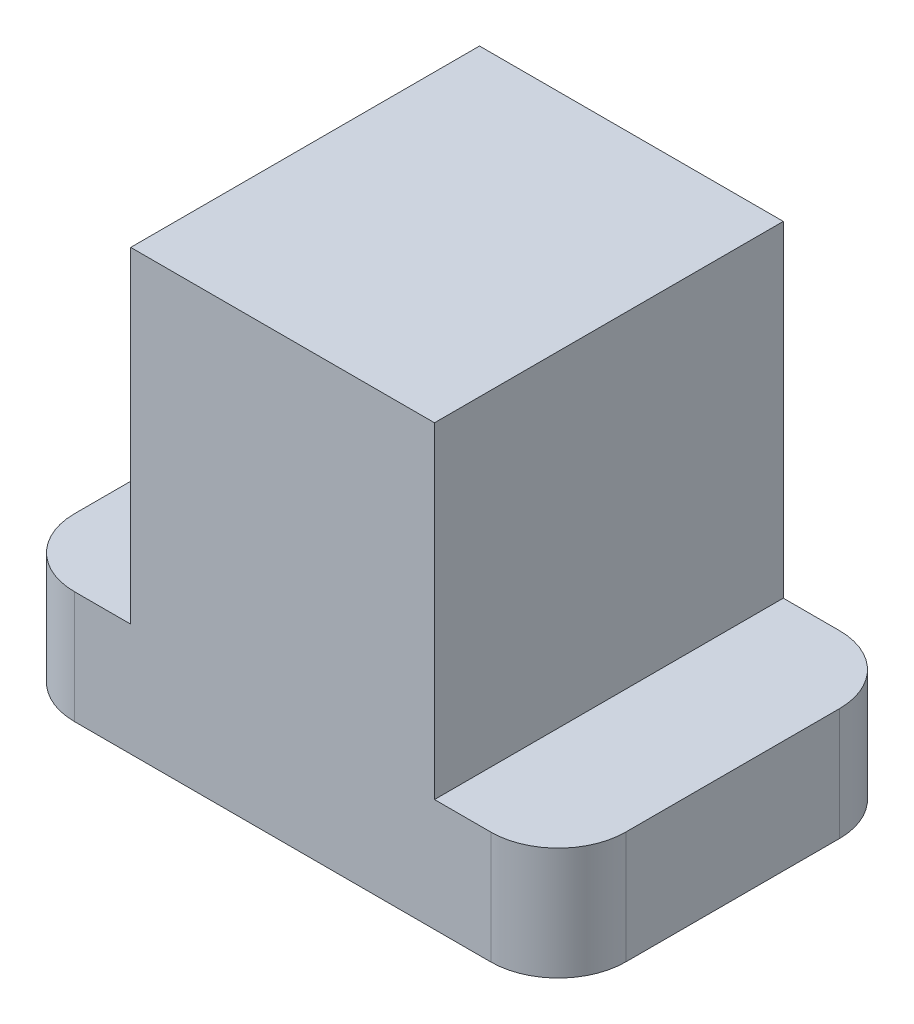
from build123d import *

# Parameters (mm, degrees)
EXTRUDE_1_DEPTH = 20
SKETCH_3_W      = 54
SKETCH_3_H      = 62
EXTRUDE_2_DEPTH = 58


with BuildPart() as part:
    # Эскиз2 → Бобышка-Вытянуть1 (new body)
    with BuildSketch(Plane(origin=(0, 0, 0), x_dir=(1, 0, 0), z_dir=(0, 1, 0))):
        with BuildLine():
            Line((-37, -31), (37, -31))
            ThreePointArc((37, -31), (45.485281374, -27.485281374), (49, -19))
            Line((49, -19), (49, 19))
            ThreePointArc((49, 19), (45.485281374, 27.485281374), (37, 31))
            Line((37, 31), (-37, 31))
            ThreePointArc((-37, 31), (-45.485281374, 27.485281374), (-49, 19))
            Line((-49, 19), (-49, -19))
            ThreePointArc((-49, -19), (-45.485281374, -27.485281374), (-37, -31))
        make_face()
    extrude(amount=EXTRUDE_1_DEPTH)

    # Эскиз3 → Бобышка-Вытянуть2 (add)
    with BuildSketch(Plane(origin=(0, 20, 0), x_dir=(1, 0, 0), z_dir=(0, 1, 0))):
        Rectangle(SKETCH_3_W, SKETCH_3_H)
    extrude(amount=EXTRUDE_2_DEPTH)


solid = part.part
